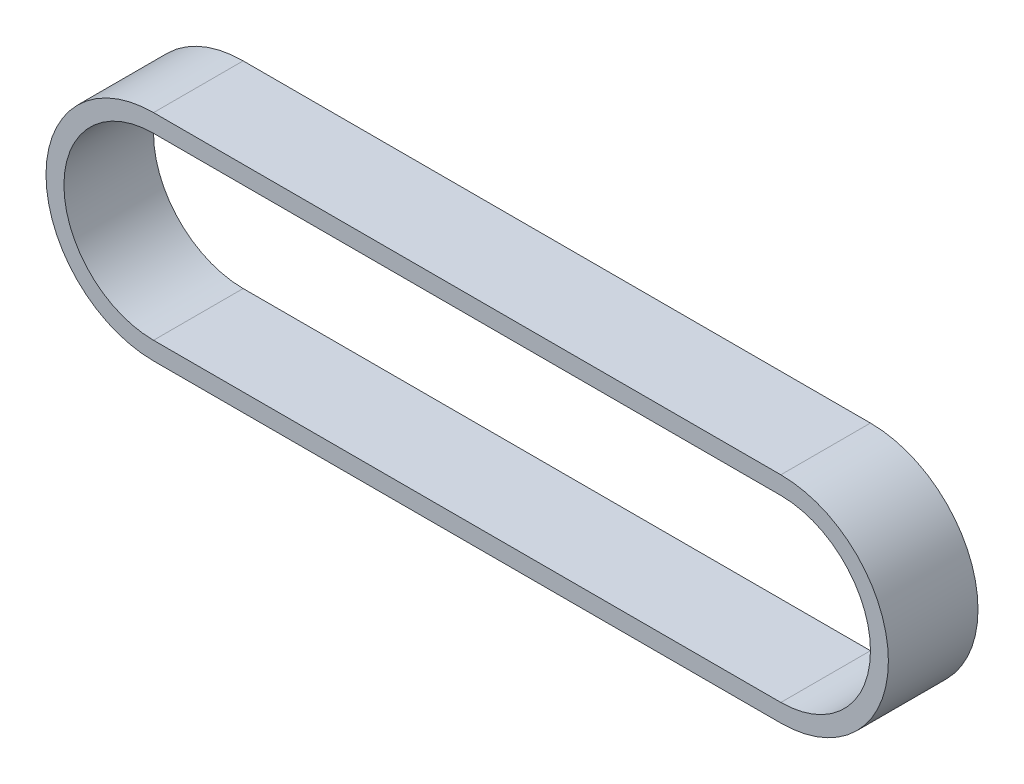
from build123d import *

# Parameters (mm, degrees)
BOSS_EXTRUDE1_DEPTH = 5


with BuildPart() as part:
    # Sketch1 → Boss-Extrude1 (new body)
    with BuildSketch(Plane.XY):
        with BuildLine():
            Line((0, 6), (35, 6))
            ThreePointArc((35, 6), (41, 0), (35, -6))
            Line((35, -6), (0, -6))
            ThreePointArc((0, -6), (-6, 0), (0, 6))
        make_face()
        with BuildLine():
            Line((0, 5), (35, 5))
            ThreePointArc((35, 5), (40, 0), (35, -5))
            Line((35, -5), (0, -5))
            ThreePointArc((0, -5), (-5, 0), (0, 5))
        make_face(mode=Mode.SUBTRACT)
    extrude(amount=BOSS_EXTRUDE1_DEPTH)


solid = part.part
